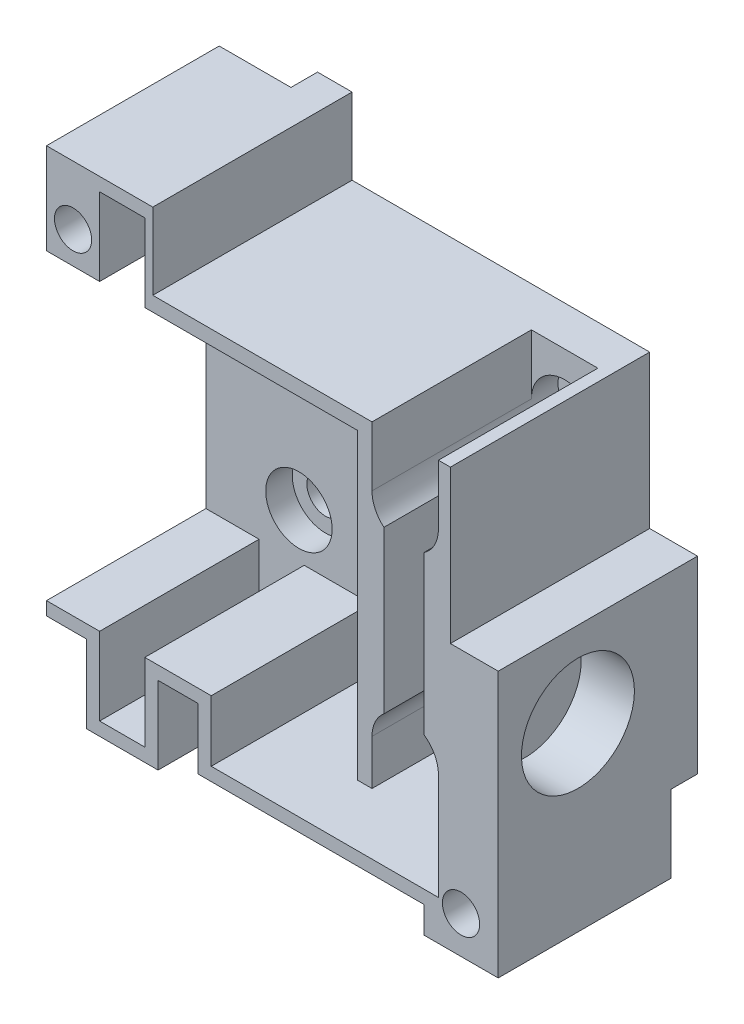
from build123d import *

# Parameters (mm, degrees)
SKETCH1_W                = 34
SKETCH1_H                = 38
BOSS_EXTRUDE1_DEPTH      = 16
SKETCH2_W                = 22.4
SKETCH2_H                = 22.8
SKETCH2_W_2              = 2.4
SKETCH2_H_2              = 4.85
CUT_EXTRUDE1_DEPTH       = 13
SKETCH3_W                = 10
SKETCH3_H                = 4.6
SKETCH3_W_2              = 3
CUT_EXTRUDE2_DEPTH       = 13
SKETCH4_R                = 1.4
CUT_EXTRUDE3_DEPTH       = 17
CUT_EXTRUDE5_DEPTH       = 2
SKETCH7_W                = 34
SKETCH7_H                = 1
CUT_EXTRUDE6_DEPTH       = 39
SKETCH9_W                = 8
SKETCH9_H                = 0.75
SKETCH9_W_2              = 5
SKETCH9_H_2              = 6.5
SKETCH9_W_3              = 3.6
SKETCH9_H_3              = 11.5
SKETCH9_W_4              = 17
SKETCH9_H_4              = 2
SKETCH9_W_5              = 3
SKETCH9_H_5              = 6.6
SKETCH9_W_6              = 5.4
CUT_EXTRUDE9_DEPTH       = 16
CUT_EXTRUDE10_DEPTH      = 13
CUT_EXTRUDE10_DEPTH_BACK = 2
SKETCH11_W               = 5
SKETCH11_H               = 4.5
CUT_EXTRUDE11_DEPTH      = 12
SKETCH12_W               = 1
SKETCH12_H               = 4.85
SKETCH12_H_2             = 22.8
CUT_EXTRUDE12_DEPTH      = 12
SKETCH14_R               = 4.25
CUT_EXTRUDE13_DEPTH      = 4
SKETCH17_W               = 3.4
SKETCH17_H               = 1
CUT_EXTRUDE16_DEPTH      = 12
SKETCH18_R               = 1.4
CUT_EXTRUDE17_DEPTH      = 12


with BuildPart() as part:
    # Sketch1 → Boss-Extrude1 (new body)
    with BuildSketch(Plane.XY):
        Rectangle(SKETCH1_W, SKETCH1_H)
    extrude(amount=BOSS_EXTRUDE1_DEPTH)

    # Sketch2 → Cut-Extrude1 (cut)
    with BuildSketch(Plane.XY.offset(16)):
        with Locations((-5.8, 0)):
            Rectangle(SKETCH2_W, SKETCH2_H)
        with Locations((-11.8, -13.825)):
            Rectangle(SKETCH2_W_2, SKETCH2_H_2)
        with Locations((-11.8, 13.825)):
            Rectangle(SKETCH2_W_2, SKETCH2_H_2)
    extrude(amount=-CUT_EXTRUDE1_DEPTH, mode=Mode.SUBTRACT)

    # Sketch3 → Cut-Extrude2 (cut)
    with BuildSketch(Plane.XY.offset(16)):
        Polygon((8.4, 19), (8.4, -11.4), (8.4, -16), (11.4, -16), (11.4, 19), align=None)
        with Locations((0.4, -13.7)):
            Rectangle(SKETCH3_W, SKETCH3_H)
        with Locations((6.9, -13.7)):
            Rectangle(SKETCH3_W_2, SKETCH3_H)
    extrude(amount=-CUT_EXTRUDE2_DEPTH, mode=Mode.SUBTRACT)

    # Sketch4 → Cut-Extrude3 (cut, through all)
    with BuildSketch(Plane.XY.offset(16)):
        with Locations((-15, 13.8)):
            Circle(SKETCH4_R)
        with Locations((14.2, -16.2)):
            Circle(SKETCH4_R)
    extrude(amount=-CUT_EXTRUDE3_DEPTH, mode=Mode.SUBTRACT)

    # Sketch5 → Cut-Extrude5 (cut)
    with BuildSketch(Plane(origin=(0, 0, 0), x_dir=(-1, 0, 0), z_dir=(0, 0, -1))):
        with BuildLine():
            Line((-14.2, -19), (-13.122967039, -19))
            ThreePointArc((-13.122967039, -19), (-11.727036304, -17.898367027), (-11.2, -16.2))
            ThreePointArc((-11.2, -16.2), (-12.078679656, -14.078679656), (-14.2, -13.2))
            Line((-14.2, -13.2), (-14.2, -14.8))
            ThreePointArc((-14.2, -14.8), (-13.210050506, -15.210050506), (-12.8, -16.2))
            ThreePointArc((-12.8, -16.2), (-13.210050506, -17.189949494), (-14.2, -17.6))
            Line((-14.2, -17.6), (-14.2, -19))
        make_face()
        with BuildLine():
            Line((-14.2, -14.8), (-14.2, -13.2))
            ThreePointArc((-14.2, -13.2), (-15.898367027, -13.727036304), (-17, -15.122967039))
            Line((-17, -15.122967039), (-17, -17.277032961))
            ThreePointArc((-17, -17.277032961), (-16.321320344, -18.321320344), (-15.277032961, -19))
            Line((-15.277032961, -19), (-14.2, -19))
            Line((-14.2, -19), (-14.2, -17.6))
            ThreePointArc((-14.2, -17.6), (-15.6, -16.2), (-14.2, -14.8))
        make_face()
        with BuildLine():
            Line((-17, -19), (-15.277032961, -19))
            ThreePointArc((-15.277032961, -19), (-16.321320344, -18.321320344), (-17, -17.277032961))
            Line((-17, -17.277032961), (-17, -19))
        make_face()
        with BuildLine():
            Line((-14.2, -13.2), (-17, -13.2))
            Line((-17, -13.2), (-17, -15.122967039))
            ThreePointArc((-17, -15.122967039), (-15.898367027, -13.727036304), (-14.2, -13.2))
        make_face()
        with BuildLine():
            Line((-17, -17.277032961), (-17, -15.122967039))
            ThreePointArc((-17, -15.122967039), (-17.2, -16.2), (-17, -17.277032961))
        make_face()
        with BuildLine():
            ThreePointArc((-14.2, -19.2), (-13.652277442, -19.149576241), (-13.122967039, -19))
            Line((-13.122967039, -19), (-14.2, -19))
            Line((-14.2, -19), (-14.2, -19.2))
        make_face()
        with BuildLine():
            ThreePointArc((-15.277032961, -19), (-14.747722558, -19.149576241), (-14.2, -19.2))
            Line((-14.2, -19.2), (-14.2, -19))
            Line((-14.2, -19), (-15.277032961, -19))
        make_face()
        with BuildLine():
            Line((-17, -19.2), (-14.2, -19.2))
            ThreePointArc((-14.2, -19.2), (-14.747722558, -19.149576241), (-15.277032961, -19))
            Line((-15.277032961, -19), (-17, -19))
            Line((-17, -19), (-17, -19.2))
        make_face()
        with BuildLine():
            ThreePointArc((-14.2, -19.2), (-13.652277442, -19.149576241), (-13.122967039, -19))
            Line((-13.122967039, -19), (-14.2, -19))
            Line((-14.2, -19), (-14.2, -19.2))
        make_face()
        with BuildLine():
            ThreePointArc((-15.277032961, -19), (-14.747722558, -19.149576241), (-14.2, -19.2))
            Line((-14.2, -19.2), (-14.2, -19))
            Line((-14.2, -19), (-15.277032961, -19))
        make_face()
        with BuildLine():
            ThreePointArc((17, 16.549545417), (18.029851482, 15.342724862), (18.4, 13.8))
            Line((18.4, 13.8), (18.4, 19))
            Line((18.4, 19), (17, 19))
            Line((17, 19), (17, 16.549545417))
        make_face()
        with BuildLine():
            ThreePointArc((11.6, 13.8), (13.457275138, 16.829851482), (17, 16.549545417))
            Line((17, 16.549545417), (17, 19))
            Line((17, 19), (11.6, 19))
            Line((11.6, 19), (11.6, 13.8))
        make_face()
        with BuildLine():
            Line((17, 11.050454583), (17, 13.8))
            Line((17, 13.8), (16.4, 13.8))
            ThreePointArc((16.4, 13.8), (15, 12.4), (13.6, 13.8))
            Line((13.6, 13.8), (11.6, 13.8))
            ThreePointArc((11.6, 13.8), (13.457275138, 10.770148518), (17, 11.050454583))
        make_face()
        with BuildLine():
            Line((16.4, 13.8), (17, 13.8))
            Line((17, 13.8), (17, 16.549545417))
            ThreePointArc((17, 16.549545417), (13.457275138, 16.829851482), (11.6, 13.8))
            Line((11.6, 13.8), (13.6, 13.8))
            ThreePointArc((13.6, 13.8), (15, 15.2), (16.4, 13.8))
        make_face()
        with BuildLine():
            ThreePointArc((17, 11.050454583), (18.029851482, 12.257275138), (18.4, 13.8))
            Line((18.4, 13.8), (17, 13.8))
            Line((17, 13.8), (17, 11.050454583))
        make_face()
        with BuildLine():
            Line((17, 13.8), (18.4, 13.8))
            ThreePointArc((18.4, 13.8), (18.029851482, 15.342724862), (17, 16.549545417))
            Line((17, 16.549545417), (17, 13.8))
        make_face()
        with BuildLine():
            ThreePointArc((17, 11.050454583), (18.029851482, 12.257275138), (18.4, 13.8))
            Line((18.4, 13.8), (17, 13.8))
            Line((17, 13.8), (17, 11.050454583))
        make_face()
        with BuildLine():
            Line((17, 13.8), (18.4, 13.8))
            ThreePointArc((18.4, 13.8), (18.029851482, 15.342724862), (17, 16.549545417))
            Line((17, 16.549545417), (17, 13.8))
        make_face()
        with BuildLine():
            Line((17, 11.050454583), (17, 13.8))
            Line((17, 13.8), (16.4, 13.8))
            ThreePointArc((16.4, 13.8), (15, 12.4), (13.6, 13.8))
            Line((13.6, 13.8), (11.6, 13.8))
            ThreePointArc((11.6, 13.8), (13.457275138, 10.770148518), (17, 11.050454583))
        make_face()
        with BuildLine():
            Line((16.4, 13.8), (17, 13.8))
            Line((17, 13.8), (17, 16.549545417))
            ThreePointArc((17, 16.549545417), (13.457275138, 16.829851482), (11.6, 13.8))
            Line((11.6, 13.8), (13.6, 13.8))
            ThreePointArc((13.6, 13.8), (15, 15.2), (16.4, 13.8))
        make_face()
        with BuildLine():
            Line((-13.122967039, -19), (-10.2, -19))
            Line((-10.2, -19), (-10.2, -13.2))
            Line((-10.2, -13.2), (-14.2, -13.2))
            ThreePointArc((-14.2, -13.2), (-12.078679656, -14.078679656), (-11.2, -16.2))
            ThreePointArc((-11.2, -16.2), (-11.727036304, -17.898367027), (-13.122967039, -19))
        make_face()
    extrude(amount=-CUT_EXTRUDE5_DEPTH, mode=Mode.SUBTRACT)

    # Sketch7 → Cut-Extrude6 (cut, through all)
    with BuildSketch(Plane(origin=(0, 19, 0), x_dir=(1, 0, 0), z_dir=(0, 1, 0))):
        with Locations((0, -15.5)):
            Rectangle(SKETCH7_W, SKETCH7_H)
    extrude(amount=-CUT_EXTRUDE6_DEPTH, mode=Mode.SUBTRACT)

    # Sketch9 → Cut-Extrude9 (cut, through all)
    with BuildSketch(Plane.XY.offset(15)):
        Polygon((8.4, 19), (-9, 19), (-9, 18.25), (-9, 12.5), (8.4, 12.5), align=None)
        with Locations((-13, 18.625)):
            Rectangle(SKETCH9_W, SKETCH9_H)
        with Locations((10.9, 15.75)):
            Rectangle(SKETCH9_W_2, SKETCH9_H_2)
        with Locations((15.2, 15.75)):
            Rectangle(SKETCH9_W_3, SKETCH9_H_2)
        with Locations((15.2, 6.75)):
            Rectangle(SKETCH9_W_3, SKETCH9_H_3)
        with Locations((2.9, -18)):
            Rectangle(SKETCH9_W_4, SKETCH9_H_4)
        with Locations((-7.1, -15.7)):
            Rectangle(SKETCH9_W_5, SKETCH9_H_5)
        with Locations((-11.3, -18.625)):
            Rectangle(SKETCH9_W_6, SKETCH9_H)
        with Locations((-15.5, -15.7)):
            Rectangle(SKETCH9_W_5, SKETCH9_H_5)
    extrude(amount=-CUT_EXTRUDE9_DEPTH, mode=Mode.SUBTRACT)

    # Sketch10 → Cut-Extrude10 (cut, two sides)
    with BuildSketch(Plane.XY.offset(3)) as cut_extrude10_sk:
        with BuildLine():
            Line((-10, 5.5), (-10, 8))
            Line((-10, 8), (-7.5, 8))
            ThreePointArc((-7.5, 8), (-11.767766953, 9.767766953), (-10, 5.5))
        make_face()
        with BuildLine():
            Line((-7.5, 8), (-10, 8))
            Line((-10, 8), (-10, 5.5))
            ThreePointArc((-10, 5.5), (-8.232233047, 6.232233047), (-7.5, 8))
        make_face()
        with BuildLine():
            Line((-10, 5.5), (-10, 8))
            Line((-10, 8), (-7.5, 8))
            ThreePointArc((-7.5, 8), (-11.767766953, 9.767766953), (-10, 5.5))
        make_face()
        with BuildLine():
            Line((-7.5, 8), (-10, 8))
            Line((-10, 8), (-10, 5.5))
            ThreePointArc((-10, 5.5), (-8.232233047, 6.232233047), (-7.5, 8))
        make_face()
        with BuildLine():
            Line((10, 8), (8.4, 8))
            Line((8.4, 8), (8.4, 6.079062729))
            ThreePointArc((8.4, 6.079062729), (9.149218941, 5.649218941), (10, 5.5))
            Line((10, 5.5), (10, 8))
        make_face()
        with BuildLine():
            Line((8.4, 9.920937271), (8.4, 8))
            Line((8.4, 8), (10, 8))
            Line((10, 8), (10, 5.5))
            ThreePointArc((10, 5.5), (10.732093302, 5.609594303), (11.4, 5.928768482))
            Line((11.4, 5.928768482), (11.4, 10.071231518))
            ThreePointArc((11.4, 10.071231518), (9.874911671, 10.496868621), (8.4, 9.920937271))
        make_face()
        with BuildLine():
            ThreePointArc((12.5, 8), (12.207940217, 9.17260394), (11.4, 10.071231518))
            Line((11.4, 10.071231518), (11.4, 5.928768482))
            ThreePointArc((11.4, 5.928768482), (12.207940217, 6.82739606), (12.5, 8))
        make_face()
        with BuildLine():
            ThreePointArc((8.4, 9.920937271), (7.736153715, 9.060660172), (7.5, 8))
            Line((7.5, 8), (8.4, 8))
            Line((8.4, 8), (8.4, 9.920937271))
        make_face()
        with BuildLine():
            Line((8.4, 8), (7.5, 8))
            ThreePointArc((7.5, 8), (7.736153715, 6.939339828), (8.4, 6.079062729))
            Line((8.4, 6.079062729), (8.4, 8))
        make_face()
        with BuildLine():
            ThreePointArc((8.4, 9.920937271), (7.736153715, 9.060660172), (7.5, 8))
            Line((7.5, 8), (8.4, 8))
            Line((8.4, 8), (8.4, 9.920937271))
        make_face()
        with BuildLine():
            Line((8.4, 8), (7.5, 8))
            ThreePointArc((7.5, 8), (7.736153715, 6.939339828), (8.4, 6.079062729))
            Line((8.4, 6.079062729), (8.4, 8))
        make_face()
        with BuildLine():
            ThreePointArc((-7.5, -8), (-8.232233047, -6.232233047), (-10, -5.5))
            Line((-10, -5.5), (-10, -8))
            Line((-10, -8), (-7.5, -8))
        make_face()
        with BuildLine():
            Line((-10, -8), (-10, -5.5))
            ThreePointArc((-10, -5.5), (-11.767766953, -9.767766953), (-7.5, -8))
            Line((-7.5, -8), (-10, -8))
        make_face()
        with BuildLine():
            ThreePointArc((-7.5, -8), (-8.232233047, -6.232233047), (-10, -5.5))
            Line((-10, -5.5), (-10, -8))
            Line((-10, -8), (-7.5, -8))
        make_face()
        with BuildLine():
            Line((-10, -8), (-10, -5.5))
            ThreePointArc((-10, -5.5), (-11.767766953, -9.767766953), (-7.5, -8))
            Line((-7.5, -8), (-10, -8))
        make_face()
        with BuildLine():
            ThreePointArc((11.4, -5.928768482), (10.732093302, -5.609594303), (10, -5.5))
            Line((10, -5.5), (10, -8))
            Line((10, -8), (8.4, -8))
            Line((8.4, -8), (8.4, -9.920937271))
            ThreePointArc((8.4, -9.920937271), (9.874911671, -10.496868621), (11.4, -10.071231518))
            Line((11.4, -10.071231518), (11.4, -5.928768482))
        make_face()
        with BuildLine():
            ThreePointArc((12.5, -8), (12.207940217, -6.82739606), (11.4, -5.928768482))
            Line((11.4, -5.928768482), (11.4, -10.071231518))
            ThreePointArc((11.4, -10.071231518), (12.207940217, -9.17260394), (12.5, -8))
        make_face()
        with BuildLine():
            ThreePointArc((10, -5.5), (9.149218941, -5.649218941), (8.4, -6.079062729))
            Line((8.4, -6.079062729), (8.4, -8))
            Line((8.4, -8), (10, -8))
            Line((10, -8), (10, -5.5))
        make_face()
        with BuildLine():
            Line((8.4, -8), (8.4, -6.079062729))
            ThreePointArc((8.4, -6.079062729), (7.736153715, -6.939339828), (7.5, -8))
            Line((7.5, -8), (8.4, -8))
        make_face()
        with BuildLine():
            Line((8.4, -8), (7.5, -8))
            ThreePointArc((7.5, -8), (7.736153715, -9.060660172), (8.4, -9.920937271))
            Line((8.4, -9.920937271), (8.4, -8))
        make_face()
        with BuildLine():
            Line((8.4, -8), (8.4, -6.079062729))
            ThreePointArc((8.4, -6.079062729), (7.736153715, -6.939339828), (7.5, -8))
            Line((7.5, -8), (8.4, -8))
        make_face()
        with BuildLine():
            Line((8.4, -8), (7.5, -8))
            ThreePointArc((7.5, -8), (7.736153715, -9.060660172), (8.4, -9.920937271))
            Line((8.4, -9.920937271), (8.4, -8))
        make_face()
    extrude(amount=CUT_EXTRUDE10_DEPTH, mode=Mode.SUBTRACT)
    extrude(cut_extrude10_sk.sketch, amount=-CUT_EXTRUDE10_DEPTH_BACK, mode=Mode.SUBTRACT)

    # Sketch11 → Cut-Extrude11 (cut)
    with BuildSketch(Plane.XY.offset(15)):
        Polygon((12.5, -8), (7.5, -8), (7.5, -11.4), (11.4, -11.4), (11.4, -16), (12.5, -16), (12.5, -11.4), align=None)
        with Locations((10, 10.25)):
            Rectangle(SKETCH11_W, SKETCH11_H)
    extrude(amount=-CUT_EXTRUDE11_DEPTH, mode=Mode.SUBTRACT)

    # Sketch12 → Cut-Extrude12 (cut)
    with BuildSketch(Plane.XY.offset(15)):
        with Locations((-10.1, 13.825)):
            Rectangle(SKETCH12_W, SKETCH12_H)
        with Locations((-10.1, -13.825)):
            Rectangle(SKETCH12_W, SKETCH12_H)
        with Locations((5.9, 0)):
            Rectangle(SKETCH12_W, SKETCH12_H_2)
    extrude(amount=-CUT_EXTRUDE12_DEPTH, mode=Mode.SUBTRACT)

    # Sketch14 → Cut-Extrude13 (cut)
    with BuildSketch(Plane(origin=(17, 0, 0), x_dir=(0, 0, -1), z_dir=(1, 0, 0))):
        with Locations((-9, -5.4)):
            Circle(SKETCH14_R)
    extrude(amount=-CUT_EXTRUDE13_DEPTH, mode=Mode.SUBTRACT)

    # Sketch17 → Cut-Extrude16 (cut)
    with BuildSketch(Plane.XY.offset(15)):
        with Locations((-11.3, 16.75)):
            Rectangle(SKETCH17_W, SKETCH17_H)
        with Locations((-11.3, -16.75)):
            Rectangle(SKETCH17_W, SKETCH17_H)
    extrude(amount=-CUT_EXTRUDE16_DEPTH, mode=Mode.SUBTRACT)

    # Sketch18 → Cut-Extrude17 (cut)
    with BuildSketch(Plane.XY.offset(1)):
        with Locations((-10, 8)):
            Circle(SKETCH18_R)
        with Locations((10, 8)):
            Circle(SKETCH18_R)
        with Locations((-10, -8)):
            Circle(SKETCH18_R)
        with Locations((10, -8)):
            Circle(SKETCH18_R)
    extrude(amount=-CUT_EXTRUDE17_DEPTH, mode=Mode.SUBTRACT)


solid = part.part
